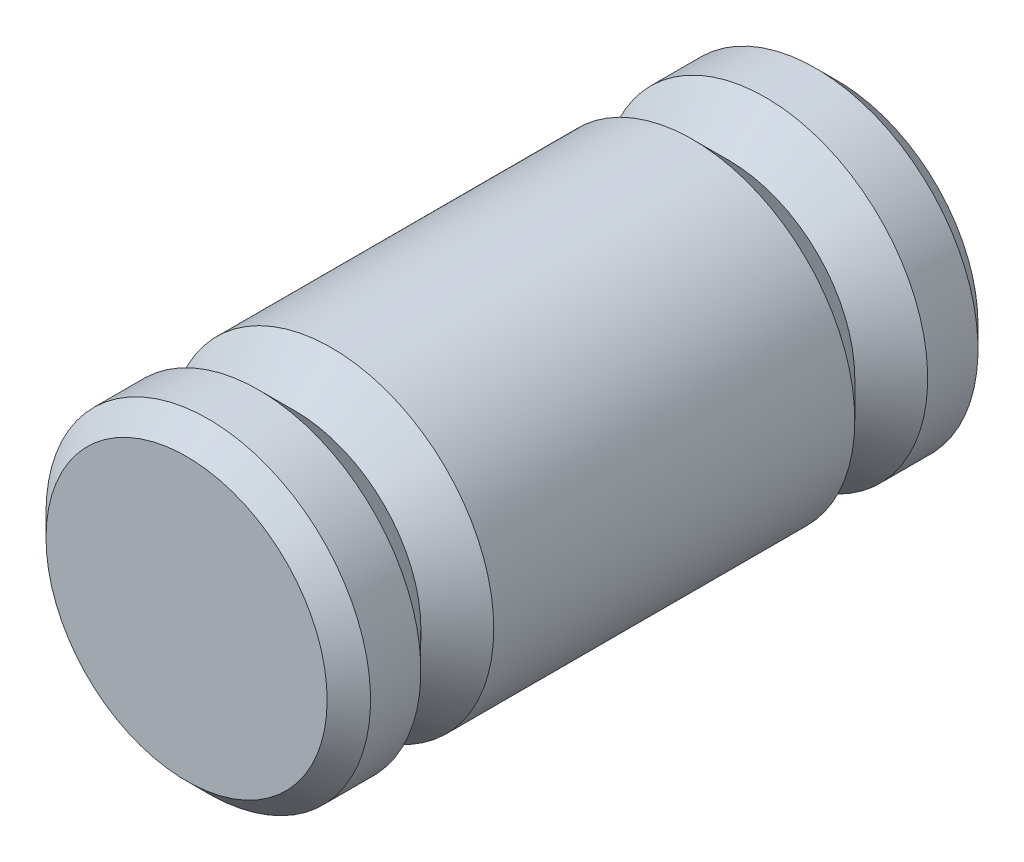
from build123d import *

# Parameters (mm, degrees)
SKETCH1_R                = 4.7498
EXTRUDE1_DEPTH           = 11.43
SKETCH3_R                = 4.7498
CUT_EXTRUDE1_DEPTH       = 1.905
CHAMFER1_SIZE            = 0.635
CHAMFER1_OF_MIRROR1_SIZE = 0.635


with BuildPart() as part:
    # Sketch1 → Extrude1 (new body)
    with BuildSketch(Plane.XY):
        with Locations((22.45995, 0)):
            Circle(SKETCH1_R)
    extrude1 = extrude(amount=EXTRUDE1_DEPTH)

    # Sketch2 → Cut-Revolve1 (revolve, cut)
    with BuildSketch(Plane(origin=(0, 0, 0), x_dir=(-1, 0, 0), z_dir=(0, 1, 0))):
        Polygon((-18.77695, 5.08), (-16.87195, 6.985), (-16.87195, 3.175), align=None)
    cut_revolve1 = revolve(axis=Axis((22.45995, 0, 11.43), (0, 0, -1)), mode=Mode.SUBTRACT)

    # Sketch3 → Cut-Extrude1 (cut)
    with BuildSketch(Plane(origin=(0, 0, 0), x_dir=(-1, 0, 0), z_dir=(0, 0, -1))):
        with Locations((-22.45995, 0)):
            Circle(SKETCH3_R)
    cut_extrude1 = extrude(amount=-CUT_EXTRUDE1_DEPTH, mode=Mode.SUBTRACT)

    # Chamfer1
    chamfer1_edges = [part.edges().sort_by_distance(p)[0] for p in [
        (17.71015, 0, 1.905),
    ]]
    chamfer(chamfer1_edges, length=CHAMFER1_SIZE)

    # Mirror1: Extrude1, Cut-Revolve1, Cut-Extrude1 across plane
    add(extrude1.mirror(Plane(origin=(28.80995, -13.97, 11.43), x_dir=(1, 0, 0), z_dir=(0, 0, -1))))
    add(cut_revolve1.mirror(Plane(origin=(28.80995, -13.97, 11.43), x_dir=(1, 0, 0), z_dir=(0, 0, -1))), mode=Mode.SUBTRACT)
    add(cut_extrude1.mirror(Plane(origin=(28.80995, -13.97, 11.43), x_dir=(1, 0, 0), z_dir=(0, 0, -1))), mode=Mode.SUBTRACT)

    # Chamfer1 of Mirror1
    chamfer1_of_mirror1_edges = [part.edges().sort_by_distance(p)[0] for p in [
        (17.71015, 0, 20.955),
    ]]
    chamfer(chamfer1_of_mirror1_edges, length=CHAMFER1_OF_MIRROR1_SIZE)


solid = part.part
